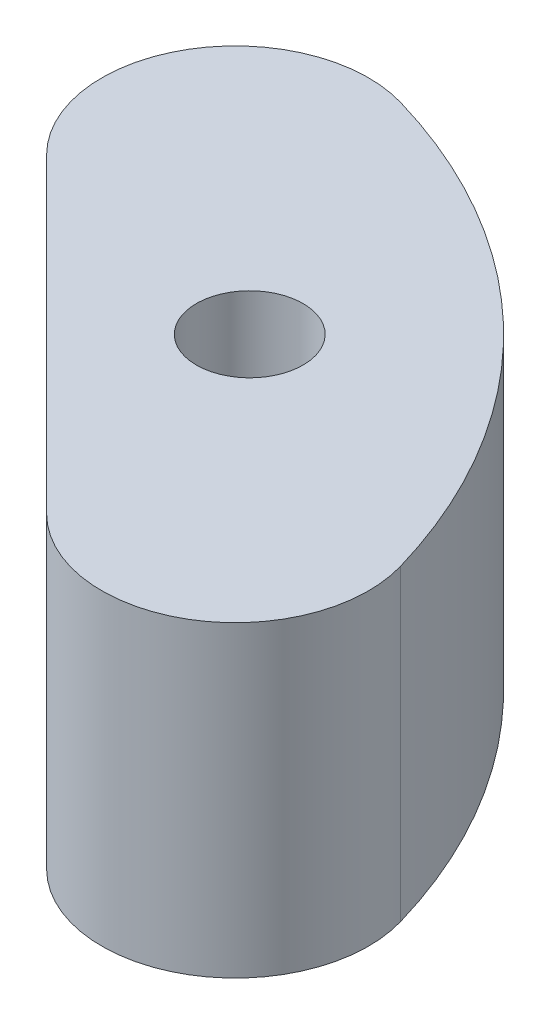
from build123d import *

# Parameters (mm, degrees)
SKETCH2_R           = 3.302
BOSS_EXTRUDE2_DEPTH = 9.525
SKETCH4_R           = 1.950000037
CUT_EXTRUDE2_DEPTH  = 5.800000084
FILLET1_R           = 8.255


with BuildPart() as part:
    # Sketch2 → Boss-Extrude2 (new body, symmetric)
    with BuildSketch(Plane(origin=(0, 0, 0), x_dir=(1, 0, 0), z_dir=(0, 1, 0))):
        with BuildLine():
            Line((-11.353721197, 34.702387112), (34.702387112, -11.353721197))
            ThreePointArc((34.702387112, -11.353721197), (25.818236348, 25.818236348), (-11.353721197, 34.702387112))
        make_face()
        with Locations((17.960512242, 17.960512242)):
            Circle(SKETCH2_R, mode=Mode.SUBTRACT)
    extrude(amount=BOSS_EXTRUDE2_DEPTH, both=True)

    # Sketch4 → Cut-Extrude2 (cut)
    with BuildSketch(Plane(origin=(11.674332957, 0, -11.674332957), x_dir=(0.707106781, 0, 0.707106781), z_dir=(-0.707106781, 0, 0.707106781))):
        with Locations((9.969999999, 6.249999946)):
            Circle(SKETCH4_R)
        with Locations((-9.969999999, 6.249999946)):
            Circle(SKETCH4_R)
        with Locations((-9.969999999, -6.249999946)):
            Circle(SKETCH4_R)
        with Locations((9.969999999, -6.249999946)):
            Circle(SKETCH4_R)
    extrude(amount=-CUT_EXTRUDE2_DEPTH, mode=Mode.SUBTRACT)

    # Fillet1
    fillet1_edges = [part.edges().sort_by_distance(p)[0] for p in [
        (34.702387112, 0, 11.353721197),
        (-11.353721197, 0, -34.702387112),
    ]]
    fillet(fillet1_edges, radius=FILLET1_R)


solid = part.part
